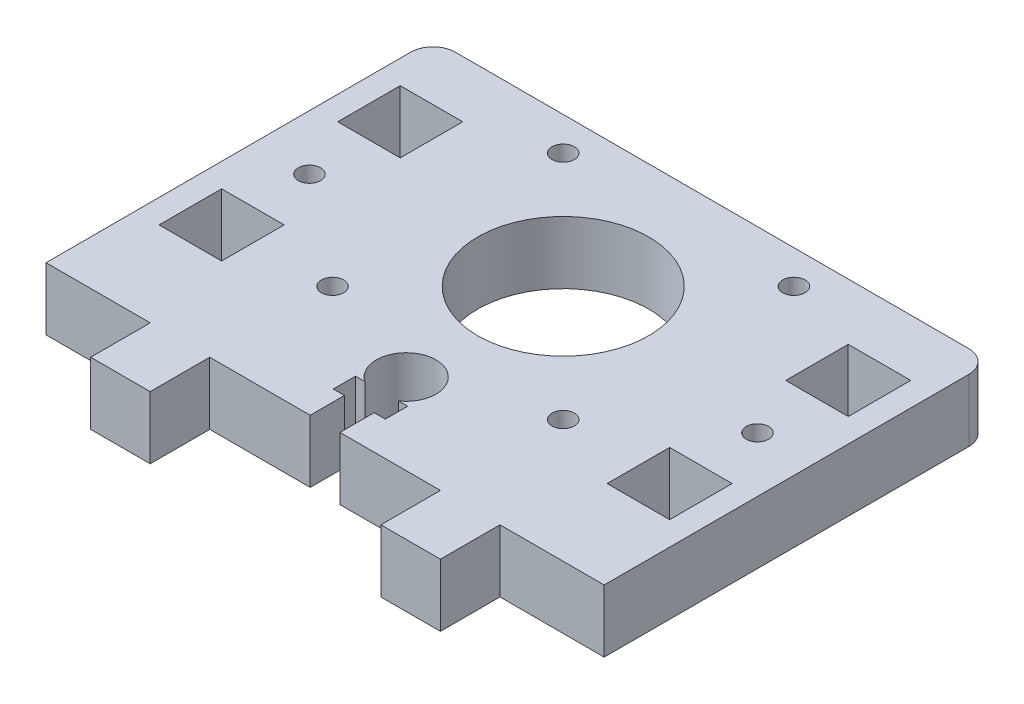
from build123d import *

# Parameters (mm, degrees)
SKETCH1_R           = 11.5
SKETCH1_R_2         = 1.5
SKETCH1_W           = 8.4
SKETCH1_H           = 8.4
BOSS_EXTRUDE1_DEPTH = 8.4


with BuildPart() as part:
    # Sketch1 → Boss-Extrude1 (new body)
    with BuildSketch(Plane(origin=(0, 0, 0), x_dir=(1, 0, 0), z_dir=(0, 1, 0))):
        with BuildLine():
            Line((-34.5, 26), (34.5, 26))
            ThreePointArc((34.5, 26), (36.621320344, 25.121320344), (37.5, 23))
            Line((37.5, 23), (37.5, -26))
            Line((37.5, -26), (23.5, -26))
            Line((23.5, -26), (23.5, -34))
            Line((23.5, -34), (15.5, -34))
            Line((15.5, -34), (15.5, -26))
            Line((15.5, -26), (2, -26))
            Line((2, -26), (2, -21.4))
            Line((2, -21.4), (3.5, -21.4))
            Line((3.5, -21.4), (3.5, -18.4))
            Line((3.5, -18.4), (2.260530911, -18.4))
            ThreePointArc((2.260530911, -18.4), (0, -11.1), (-2.260530911, -18.4))
            Line((-2.260530911, -18.4), (-3.5, -18.4))
            Line((-3.5, -18.4), (-3.5, -21.4))
            Line((-3.5, -21.4), (-2, -21.4))
            Line((-2, -21.4), (-2, -26))
            Line((-2, -26), (-15.5, -26))
            Line((-15.5, -26), (-15.5, -34))
            Line((-15.5, -34), (-23.5, -34))
            Line((-23.5, -34), (-23.5, -26))
            Line((-23.5, -26), (-37.5, -26))
            Line((-37.5, -26), (-37.5, 23))
            ThreePointArc((-37.5, 23), (-36.621320344, 25.121320344), (-34.5, 26))
        make_face()
        with Locations((0, 6)):
            Circle(SKETCH1_R, mode=Mode.SUBTRACT)
        with Locations((15.5, 21.5)):
            Circle(SKETCH1_R_2, mode=Mode.SUBTRACT)
        with Locations((-15.5, 21.5)):
            Circle(SKETCH1_R_2, mode=Mode.SUBTRACT)
        with Locations((15.5, -9.5)):
            Circle(SKETCH1_R_2, mode=Mode.SUBTRACT)
        with Locations((-15.5, -9.5)):
            Circle(SKETCH1_R_2, mode=Mode.SUBTRACT)
        with Locations((-30.1, 2)):
            Circle(SKETCH1_R_2, mode=Mode.SUBTRACT)
        with Locations((30.1, 2)):
            Circle(SKETCH1_R_2, mode=Mode.SUBTRACT)
        with Locations((-30.1, 14.2)):
            Rectangle(SKETCH1_W, SKETCH1_H, mode=Mode.SUBTRACT)
        with Locations((-30.1, -9.8)):
            Rectangle(SKETCH1_W, SKETCH1_H, mode=Mode.SUBTRACT)
        with Locations((30.1, -9.8)):
            Rectangle(SKETCH1_W, SKETCH1_H, mode=Mode.SUBTRACT)
        with Locations((30.1, 14.2)):
            Rectangle(SKETCH1_W, SKETCH1_H, mode=Mode.SUBTRACT)
    extrude(amount=BOSS_EXTRUDE1_DEPTH)


solid = part.part
